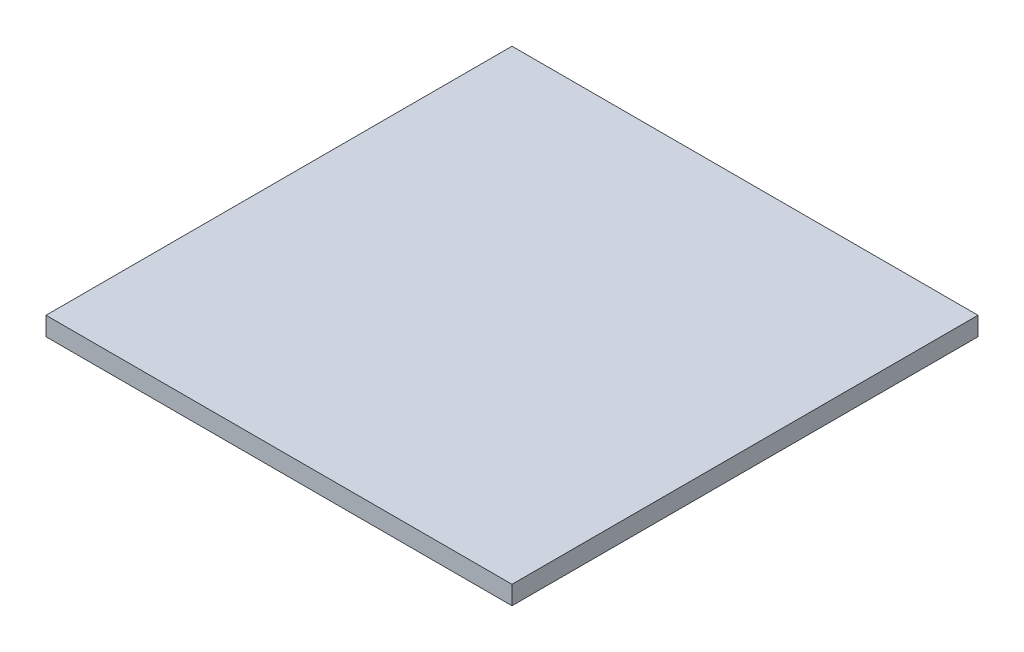
from build123d import *

# Parameters (mm, degrees)
SKETCH1_W           = 5
SKETCH1_H           = 5
BOSS_EXTRUDE1_DEPTH = 0.2


with BuildPart() as part:
    # Sketch1 → Boss-Extrude1 (new body)
    with BuildSketch(Plane(origin=(0, 0, 0), x_dir=(1, 0, 0), z_dir=(0, 1, 0))):
        Rectangle(SKETCH1_W, SKETCH1_H)
    extrude(amount=BOSS_EXTRUDE1_DEPTH)


solid = part.part
